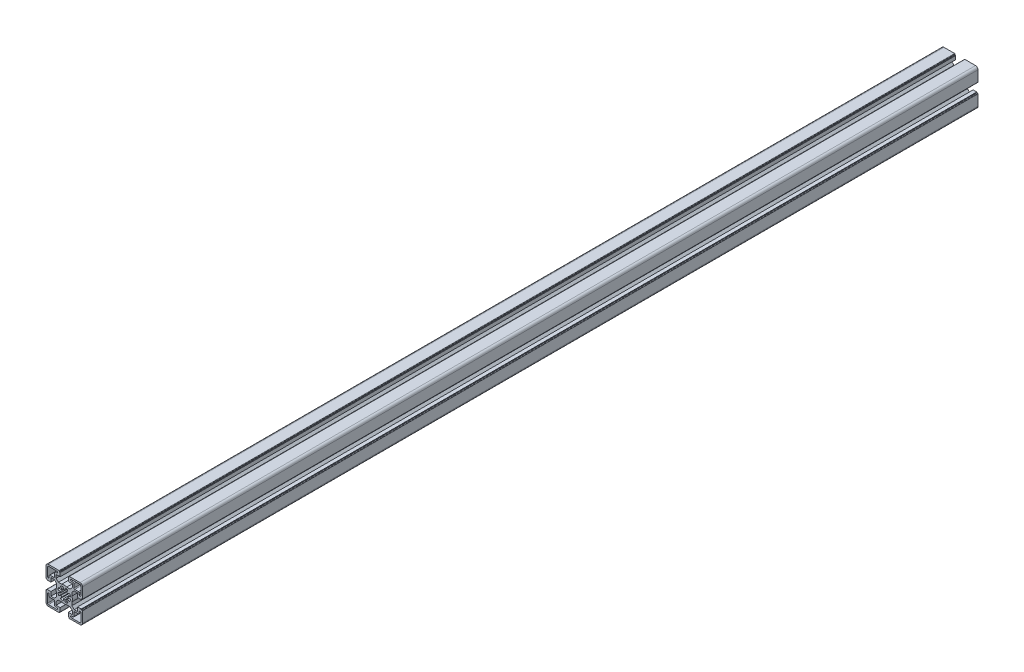
from build123d import *

# Parameters (mm, degrees)
BASE_EXTRUDE_DEPTH = 1106


with BuildPart() as part:
    # Sketch1 → Base-Extrude (new body)
    with BuildSketch(Plane.XY):
        with BuildLine():
            Line((-4.99999574, -16.499883971), (-4.99999574, -20.99990968))
            Line((-4.99999574, -20.99990968), (-5.80004044, -20.99990968))
            Line((-5.80004044, -20.99990968), (-5.80004044, -21.999970054))
            ThreePointArc((-5.80004044, -21.999970054), (-5.946487232, -22.353523887), (-6.300041066, -22.49997068))
            Line((-6.300041066, -22.49997068), (-19.500014911, -22.49997068))
            ThreePointArc((-19.500014911, -22.49997068), (-21.62133367, -21.62129168), (-22.50001267, -19.499972921))
            Line((-22.50001267, -19.499972921), (-22.50001267, -6.299929564))
            ThreePointArc((-22.50001267, -6.299929564), (-22.353566213, -5.946376541), (-22.00001319, -5.799930084))
            Line((-22.00001319, -5.799930084), (-21.000012806, -5.799930084))
            Line((-21.000012806, -5.799930084), (-21.000012806, -4.999940084))
            Line((-21.000012806, -4.999940084), (-16.500012806, -4.999940084))
            Line((-16.500012806, -4.999940084), (-16.500012806, -10.049940084))
            Line((-16.500012806, -10.049940084), (-12.342923806, -10.049940084))
            Line((-12.342923806, -10.049940084), (-9.499953806, -7.206970084))
            Line((-9.499953806, -7.206970084), (-9.499953806, -3.122617084))
            ThreePointArc((-9.499953806, -3.122617084), (-10.000013376, 6.1916e-05), (-9.499953806, 3.122740916))
            Line((-9.499953806, 3.122740916), (-9.499953806, 7.206970084))
            Line((-9.499953806, 7.206970084), (-12.342923806, 10.049940084))
            Line((-12.342923806, 10.049940084), (-16.500012806, 10.049940084))
            Line((-16.500012806, 10.049940084), (-16.500012806, 4.999940084))
            Line((-16.500012806, 4.999940084), (-21.000012806, 4.999940084))
            Line((-21.000012806, 4.999940084), (-21.000012806, 5.799930084))
            Line((-21.000012806, 5.799930084), (-22.00001319, 5.799930084))
            ThreePointArc((-22.00001319, 5.799930084), (-22.353566213, 5.946376541), (-22.50001267, 6.299929564))
            Line((-22.50001267, 6.299929564), (-22.50001267, 19.499972921))
            ThreePointArc((-22.50001267, 19.499972921), (-21.62133367, 21.62129168), (-19.500014911, 22.49997068))
            Line((-19.500014911, 22.49997068), (-6.299954884, 22.49997068))
            ThreePointArc((-6.299954884, 22.49997068), (-5.946364566, 22.353508775), (-5.799902661, 21.999918456))
            Line((-5.799902661, 21.999918456), (-5.799902661, 20.999918083))
            Line((-5.799902661, 20.999918083), (-4.99999574, 20.999918083))
            Line((-4.99999574, 20.999918083), (-4.99999574, 16.499989166))
            Line((-4.99999574, 16.499989166), (-10.050086009, 16.499989166))
            Line((-10.050086009, 16.499989166), (-10.050086009, 12.342794971))
            Line((-10.050086009, 12.342794971), (-7.207151696, 9.499860659))
            Line((-7.207151696, 9.499860659), (-3.122798696, 9.499860659))
            ThreePointArc((-3.122798696, 9.499860659), (-0.000120196, 9.999920064), (3.122558304, 9.499860659))
            Line((3.122558304, 9.499860659), (7.206958901, 9.499860659))
            Line((7.206958901, 9.499860659), (10.049884116, 12.342787875))
            Line((10.049884116, 12.342787875), (10.049884116, 16.499989166))
            Line((10.049884116, 16.499989166), (4.99999574, 16.499989166))
            Line((4.99999574, 16.499989166), (4.99999574, 20.999963909))
            Line((4.99999574, 20.999963909), (5.799902661, 20.999963909))
            Line((5.799902661, 20.999963909), (5.799902661, 21.999918456))
            ThreePointArc((5.799902661, 21.999918456), (5.946364566, 22.353508775), (6.299954884, 22.49997068))
            Line((6.299954884, 22.49997068), (19.500081571, 22.49997068))
            ThreePointArc((19.500081571, 22.49997068), (21.62140033, 21.62129168), (22.50007933, 19.499972921))
            Line((22.50007933, 19.499972921), (22.50007933, 6.299877709))
            ThreePointArc((22.50007933, 6.299877709), (22.35363283, 5.946324583), (22.000079704, 5.799878083))
            Line((22.000079704, 5.799878083), (20.999995421, 5.799878083))
            Line((20.999995421, 5.799878083), (20.999995421, 4.999941084))
            Line((20.999995421, 4.999941084), (16.499983596, 4.999941084))
            Line((16.499983596, 4.999941084), (16.499983596, 10.049940084))
            Line((16.499983596, 10.049940084), (12.342894596, 10.049940084))
            Line((12.342894596, 10.049940084), (9.499922596, 7.206970084))
            Line((9.499922596, 7.206970084), (9.499922596, 3.122735916))
            ThreePointArc((9.499922596, 3.122735916), (9.999982165, 5.6916e-05), (9.499922596, -3.122622084))
            Line((9.499922596, -3.122622084), (9.499922596, -7.206970084))
            Line((9.499922596, -7.206970084), (12.342894596, -10.049940084))
            Line((12.342894596, -10.049940084), (16.499983596, -10.049940084))
            Line((16.499983596, -10.049940084), (16.499983596, -4.999941084))
            Line((16.499983596, -4.999941084), (20.999995421, -4.999941084))
            Line((20.999995421, -4.999941084), (20.999995421, -5.799878083))
            Line((20.999995421, -5.799878083), (22.000079704, -5.799878083))
            ThreePointArc((22.000079704, -5.799878083), (22.35363283, -5.946324583), (22.50007933, -6.299877709))
            Line((22.50007933, -6.299877709), (22.50007933, -19.499973421))
            ThreePointArc((22.50007933, -19.499973421), (21.621400476, -21.621291826), (19.500082071, -22.49997068))
            Line((19.500082071, -22.49997068), (6.300041066, -22.49997068))
            ThreePointArc((6.300041066, -22.49997068), (5.946487232, -22.353523887), (5.80004044, -21.999970054))
            Line((5.80004044, -21.999970054), (5.80004044, -20.99990968))
            Line((5.80004044, -20.99990968), (4.99999574, -20.99990968))
            Line((4.99999574, -20.99990968), (4.99999574, -16.499883971))
            Line((4.99999574, -16.499883971), (10.049884116, -16.499883971))
            Line((10.049884116, -16.499883971), (10.049884116, -12.342787875))
            Line((10.049884116, -12.342787875), (7.206933602, -9.49983536))
            Line((7.206933602, -9.49983536), (3.122579602, -9.49983536))
            ThreePointArc((3.122579602, -9.49983536), (-9.9398e-05, -9.99989493), (-3.122778398, -9.49983536))
            Line((-3.122778398, -9.49983536), (-7.207126398, -9.49983536))
            Line((-7.207126398, -9.49983536), (-10.050086009, -12.342794971))
            Line((-10.050086009, -12.342794971), (-10.050086009, -16.499883971))
            Line((-10.050086009, -16.499883971), (-4.99999574, -16.499883971))
        make_face()
        with BuildLine():
            Line((0.868239441, 4.924019626), (1.389186106, 7.878448412))
            ThreePointArc((1.389186106, 7.878448412), (3.061471579, 7.391020172), (4.588617704, 6.553195784))
            Line((4.588617704, 6.553195784), (2.867879873, 4.095738521))
            ThreePointArc((2.867879873, 4.095738521), (3.535523556, 3.535517244), (4.095743641, 2.867872561))
            Line((4.095743641, 2.867872561), (6.553203976, 4.588606005))
            ThreePointArc((6.553203976, 4.588606005), (7.391023332, 3.061463952), (7.878448799, 1.389183909))
            Line((7.878448799, 1.389183909), (4.924019868, 0.868238068))
            ThreePointArc((4.924019868, 0.868238068), (4.9999809, 7.81e-07), (4.924020139, -0.868236529))
            Line((4.924020139, -0.868236529), (7.878449234, -1.389181447))
            ThreePointArc((7.878449234, -1.389181447), (7.391025132, -3.061459606), (6.553207937, -4.588600349))
            Line((6.553207937, -4.588600349), (4.095746117, -2.867869026))
            ThreePointArc((4.095746117, -2.867869026), (3.535522832, -3.535517968), (2.86787466, -4.095742171))
            Line((2.86787466, -4.095742171), (4.588609364, -6.553201624))
            ThreePointArc((4.588609364, -6.553201624), (3.061466598, -7.391022236), (1.389185513, -7.878448517))
            Line((1.389185513, -7.878448517), (0.868239071, -4.924019691))
            ThreePointArc((0.868239071, -4.924019691), (8.15e-07, -4.9999809), (-0.868237465, -4.924019974))
            Line((-0.868237465, -4.924019974), (-1.389182943, -7.87844897))
            ThreePointArc((-1.389182943, -7.87844897), (-3.06146423, -7.391023216), (-4.588607303, -6.553203067))
            Line((-4.588607303, -6.553203067), (-2.867873372, -4.095743073))
            ThreePointArc((-2.867873372, -4.095743073), (-3.535520061, -3.535520739), (-4.095742523, -2.867874158))
            Line((-4.095742523, -2.867874158), (-6.553202186, -4.588608561))
            ThreePointArc((-6.553202186, -4.588608561), (-7.391024272, -3.061461681), (-7.878450195, -1.389175997))
            Line((-7.878450195, -1.389175997), (-4.92402074, -0.868233124))
            ThreePointArc((-4.92402074, -0.868233124), (-4.9999809, 1.729e-06), (-4.924020139, 0.868236529))
            Line((-4.924020139, 0.868236529), (-7.878449234, 1.389181447))
            ThreePointArc((-7.878449234, 1.389181447), (-7.391023494, 3.061463561), (-6.553203027, 4.588607361))
            Line((-6.553203027, 4.588607361), (-4.095743048, 2.867873408))
            ThreePointArc((-4.095743048, 2.867873408), (-3.535525782, 3.535515019), (-2.867885877, 4.095734317))
            Line((-2.867885877, 4.095734317), (-4.588627311, 6.553189058))
            ThreePointArc((-4.588627311, 6.553189058), (-3.061465289, 7.391022778), (-1.389161147, 7.878452813))
            Line((-1.389161147, 7.878452813), (-0.868223842, 4.924022376))
            ThreePointArc((-0.868223842, 4.924022376), (7.92e-06, 4.9999809), (0.868239441, 4.924019626))
        make_face(mode=Mode.SUBTRACT)
        with BuildLine():
            Line((-17.500118733, -12.000017917), (-13.000117238, -12.000017917))
            ThreePointArc((-13.000117238, -12.000017917), (-12.293010985, -12.292910917), (-12.000117985, -13.00001717))
            Line((-12.000117985, -13.00001717), (-12.000117985, -17.49992083))
            ThreePointArc((-12.000117985, -17.49992083), (-11.707224985, -18.207027083), (-11.000118733, -18.499920083))
            Line((-11.000118733, -18.499920083), (-9.000117985, -18.499920083))
            ThreePointArc((-9.000117985, -18.499920083), (-8.000069068, -19.499969), (-9.000117985, -20.500017917))
            Line((-9.000117985, -20.500017917), (-19.500118733, -20.500017917))
            ThreePointArc((-19.500118733, -20.500017917), (-20.207224985, -20.207124917), (-20.500117985, -19.500018664))
            Line((-20.500117985, -19.500018664), (-20.500117985, -8.999920083))
            ThreePointArc((-20.500117985, -8.999920083), (-19.500117985, -7.999920083), (-18.500117985, -8.999920083))
            Line((-18.500117985, -8.999920083), (-18.500117985, -11.000018664))
            ThreePointArc((-18.500117985, -11.000018664), (-18.207224985, -11.707124917), (-17.500118733, -12.000017917))
        make_face(mode=Mode.SUBTRACT)
        with BuildLine():
            Line((13.000003267, -12.000017917), (17.500004762, -12.000017917))
            ThreePointArc((17.500004762, -12.000017917), (18.207111015, -11.707124917), (18.500004015, -11.000018664))
            Line((18.500004015, -11.000018664), (18.500004015, -9.000115751))
            ThreePointArc((18.500004015, -9.000115751), (19.500004015, -8.000115751), (20.500004015, -9.000115751))
            Line((20.500004015, -9.000115751), (20.500004015, -19.500018664))
            ThreePointArc((20.500004015, -19.500018664), (20.207111015, -20.207124917), (19.500004762, -20.500017917))
            Line((19.500004762, -20.500017917), (9.000004015, -20.500017917))
            ThreePointArc((9.000004015, -20.500017917), (7.999955097, -19.499969), (9.000004015, -18.499920083))
            Line((9.000004015, -18.499920083), (11.000004762, -18.499920083))
            ThreePointArc((11.000004762, -18.499920083), (11.707111015, -18.207027083), (12.000004015, -17.49992083))
            Line((12.000004015, -17.49992083), (12.000004015, -13.00001717))
            ThreePointArc((12.000004015, -13.00001717), (12.292897015, -12.292910917), (13.000003267, -12.000017917))
        make_face(mode=Mode.SUBTRACT)
        with BuildLine():
            Line((-17.500118733, 12.000017917), (-13.000117238, 12.000017917))
            ThreePointArc((-13.000117238, 12.000017917), (-12.293010985, 12.292910917), (-12.000117985, 13.00001717))
            Line((-12.000117985, 13.00001717), (-12.000117985, 17.49992083))
            ThreePointArc((-12.000117985, 17.49992083), (-11.707224985, 18.207027083), (-11.000118733, 18.499920083))
            Line((-11.000118733, 18.499920083), (-9.000117985, 18.499920083))
            ThreePointArc((-9.000117985, 18.499920083), (-8.000069068, 19.499969), (-9.000117985, 20.500017917))
            Line((-9.000117985, 20.500017917), (-19.500118733, 20.500017917))
            ThreePointArc((-19.500118733, 20.500017917), (-20.207224985, 20.207124917), (-20.500117985, 19.500018664))
            Line((-20.500117985, 19.500018664), (-20.500117985, 8.999920083))
            ThreePointArc((-20.500117985, 8.999920083), (-19.500117985, 7.999920083), (-18.500117985, 8.999920083))
            Line((-18.500117985, 8.999920083), (-18.500117985, 11.000018664))
            ThreePointArc((-18.500117985, 11.000018664), (-18.207224985, 11.707124917), (-17.500118733, 12.000017917))
        make_face(mode=Mode.SUBTRACT)
        with BuildLine():
            Line((13.000003267, 12.000017917), (17.500004762, 12.000017917))
            ThreePointArc((17.500004762, 12.000017917), (18.207111015, 11.707124917), (18.500004015, 11.000018664))
            Line((18.500004015, 11.000018664), (18.500004015, 9.000115751))
            ThreePointArc((18.500004015, 9.000115751), (19.500004015, 8.000115751), (20.500004015, 9.000115751))
            Line((20.500004015, 9.000115751), (20.500004015, 19.500018664))
            ThreePointArc((20.500004015, 19.500018664), (20.207111015, 20.207124917), (19.500004762, 20.500017917))
            Line((19.500004762, 20.500017917), (9.000004015, 20.500017917))
            ThreePointArc((9.000004015, 20.500017917), (7.999955097, 19.499969), (9.000004015, 18.499920083))
            Line((9.000004015, 18.499920083), (11.000004762, 18.499920083))
            ThreePointArc((11.000004762, 18.499920083), (11.707111015, 18.207027083), (12.000004015, 17.49992083))
            Line((12.000004015, 17.49992083), (12.000004015, 13.00001717))
            ThreePointArc((12.000004015, 13.00001717), (12.292897015, 12.292910917), (13.000003267, 12.000017917))
        make_face(mode=Mode.SUBTRACT)
    extrude(amount=BASE_EXTRUDE_DEPTH)


solid = part.part
